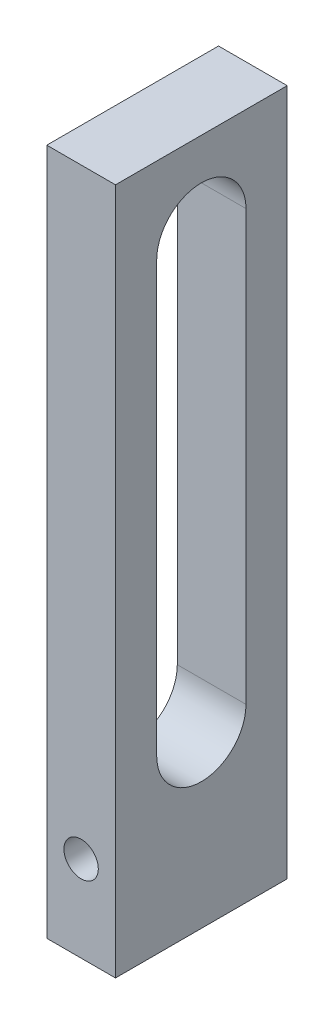
from build123d import *

# Parameters (mm, degrees)
SKETCH1_W         = 8
SKETCH1_H         = 80
SKETCH1_R         = 2
MAIN_DEPTH        = 10
FIXHOLE_REACH     = 82
SKETCH3_R         = 1.25
ROLLINGHOLE_DEPTH = 9


with BuildPart() as part:
    # Sketch1 → Main (new body, symmetric)
    with BuildSketch(Plane.XY):
        with Locations((0, 30)):
            Rectangle(SKETCH1_W, SKETCH1_H)
        Circle(SKETCH1_R, mode=Mode.SUBTRACT)
    extrude(amount=MAIN_DEPTH, both=True)

    # Sketch3 → FixHole (cut, up to next)
    with BuildSketch(Plane(origin=(0, -10, 0), x_dir=(-1, 0, 0), z_dir=(0, -1, 0)), mode=Mode.PRIVATE) as fixhole_sk1:
        Circle(SKETCH3_R)
    fixhole_tool1 = extrude(fixhole_sk1.sketch, amount=-FIXHOLE_REACH, mode=Mode.PRIVATE) & part.part
    add(fixhole_tool1.solids().sort_by_distance((0, -10, 0))[0], mode=Mode.SUBTRACT)

    # Sketch4 → RollingHole (cut, through all)
    with BuildSketch(Plane.ZY.offset(4)):
        with BuildLine():
            Line((-5.2, 10), (-5.2, 60))
            ThreePointArc((-5.2, 60), (0, 65.2), (5.2, 60))
            Line((5.2, 60), (5.2, 10))
            ThreePointArc((5.2, 10), (0, 4.8), (-5.2, 10))
        make_face()
    extrude(amount=-ROLLINGHOLE_DEPTH, mode=Mode.SUBTRACT)


solid = part.part
